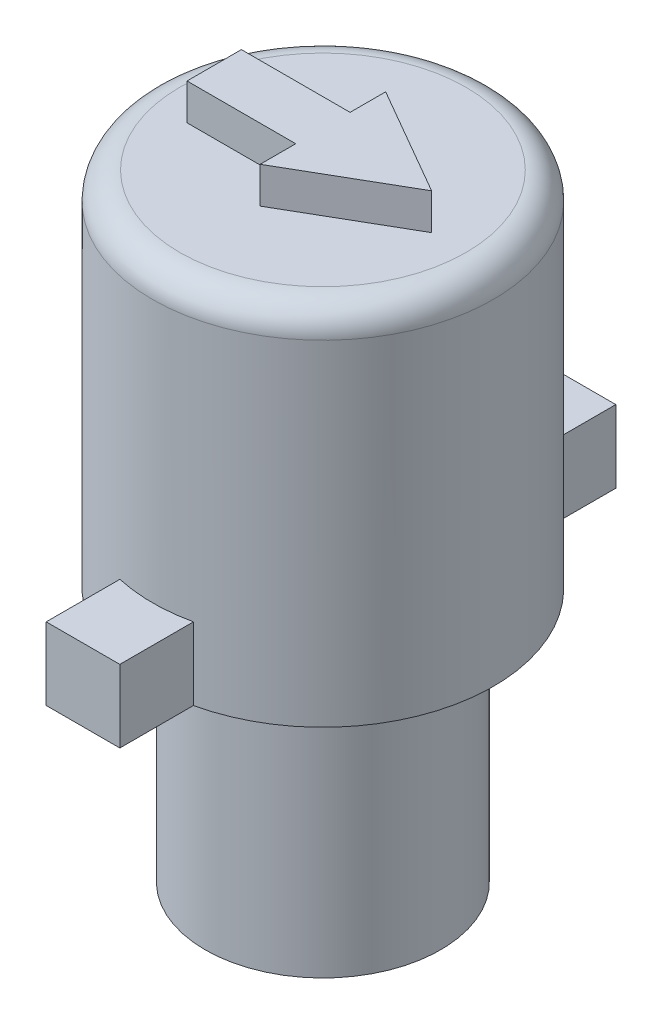
from build123d import *

# Parameters (mm, degrees)
SKETCH1_R           = 3.25
BOSS_EXTRUDE1_DEPTH = 7.018
SKETCH6_R           = 4.7
BOSS_EXTRUDE2_DEPTH = 10
FILLET1_R           = 0.75
BOSS_EXTRUDE3_DEPTH = 1
BOSS_EXTRUDE4_DEPTH = 2


with BuildPart() as part:
    # Sketch1 → Boss-Extrude1 (new body)
    with BuildSketch(Plane(origin=(0, 0, 0), x_dir=(1, 0, 0), z_dir=(0, 1, 0))):
        Circle(SKETCH1_R)
    extrude(amount=BOSS_EXTRUDE1_DEPTH)

    # Sketch6 → Boss-Extrude2 (add)
    with BuildSketch(Plane(origin=(0, 7.018, 0), x_dir=(1, 0, 0), z_dir=(0, 1, 0))):
        Circle(SKETCH6_R)
    extrude(amount=BOSS_EXTRUDE2_DEPTH)

    # Fillet1
    fillet1_edges = [part.edges().sort_by_distance(p)[0] for p in [
        (-4.7, 17.018, 0),
    ]]
    fillet(fillet1_edges, radius=FILLET1_R)

    # Sketch8 → Boss-Extrude3 (add)
    with BuildSketch(Plane(origin=(0, 17.018, 0), x_dir=(1, 0, 0), z_dir=(0, 1, 0))):
        Polygon((0, 0.75), (-3, 0.75), (-3, -0.75), (0, -0.75), (0, -1.732050808), (3, 0), (0, 1.732050808), align=None)
    extrude(amount=BOSS_EXTRUDE3_DEPTH)

    # Sketch9 → Boss-Extrude4 (add)
    with BuildSketch(Plane.XZ.offset(-7.018)):
        with BuildLine():
            Line((-1.016, 4.588871757), (-1.016, 6.620871757))
            Line((-1.016, 6.620871757), (1.016, 6.620871757))
            Line((1.016, 6.620871757), (1.016, 4.588871757))
            ThreePointArc((1.016, 4.588871757), (0, 4.7), (-1.016, 4.588871757))
        make_face()
        with BuildLine():
            Line((-1.651, -4.400477133), (-1.651, -6.432477133))
            Line((-1.651, -6.432477133), (1.651, -6.432477133))
            Line((1.651, -6.432477133), (1.651, -4.400477133))
            ThreePointArc((1.651, -4.400477133), (0, -4.7), (-1.651, -4.400477133))
        make_face()
    extrude(amount=-BOSS_EXTRUDE4_DEPTH)


solid = part.part
